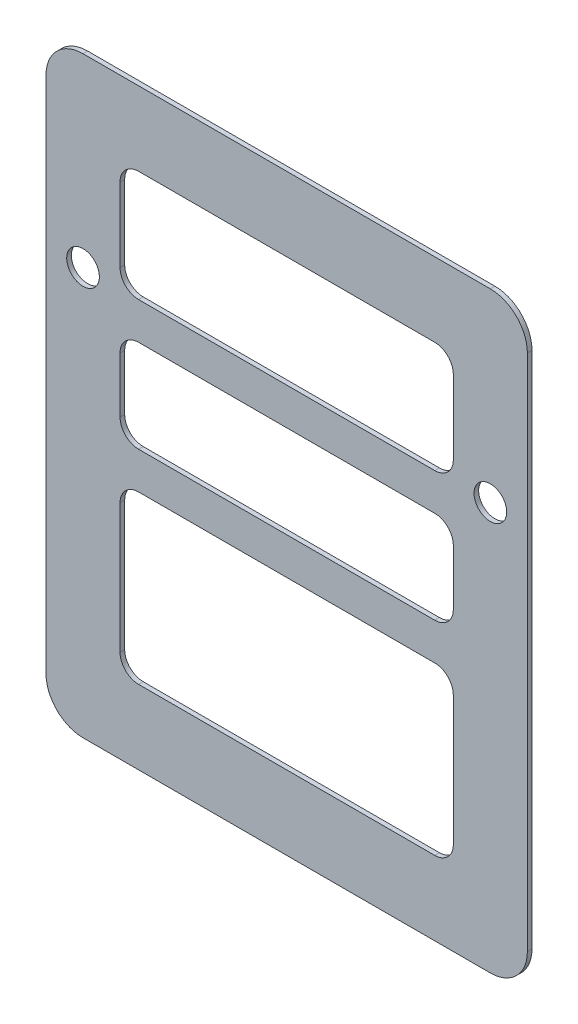
from build123d import *

# Parameters (mm, degrees)
SKETCH1_R           = 11.2
BOSS_EXTRUDE1_DEPTH = 3.175


with BuildPart() as part:
    # Sketch1 → Boss-Extrude1 (new body)
    with BuildSketch(Plane.XY):
        with BuildLine():
            Line((-139.7, -203.2), (139.7, -203.2))
            ThreePointArc((139.7, -203.2), (157.660512242, -195.760512242), (165.1, -177.8))
            Line((165.1, -177.8), (165.1, 177.8))
            ThreePointArc((165.1, 177.8), (157.660512242, 195.760512242), (139.7, 203.2))
            Line((139.7, 203.2), (-139.7, 203.2))
            ThreePointArc((-139.7, 203.2), (-157.660512242, 195.760512242), (-165.1, 177.8))
            Line((-165.1, 177.8), (-165.1, -177.8))
            ThreePointArc((-165.1, -177.8), (-157.660512242, -195.760512242), (-139.7, -203.2))
        make_face()
        with Locations((-139.7, 76.2)):
            Circle(SKETCH1_R, mode=Mode.SUBTRACT)
        with Locations((139.7, 76.2)):
            Circle(SKETCH1_R, mode=Mode.SUBTRACT)
        with BuildLine():
            Line((-101.6, -152.4), (101.6, -152.4))
            ThreePointArc((101.6, -152.4), (110.580256121, -148.680256121), (114.3, -139.7))
            Line((114.3, -139.7), (114.3, -50.8))
            ThreePointArc((114.3, -50.8), (110.580256121, -41.819743879), (101.6, -38.1))
            Line((101.6, -38.1), (-101.6, -38.1))
            ThreePointArc((-101.6, -38.1), (-110.580256121, -41.819743879), (-114.3, -50.8))
            Line((-114.3, -50.8), (-114.3, -139.7))
            ThreePointArc((-114.3, -139.7), (-110.580256121, -148.680256121), (-101.6, -152.4))
        make_face(mode=Mode.SUBTRACT)
        with BuildLine():
            Line((-101.6, -12.7), (101.6, -12.7))
            ThreePointArc((101.6, -12.7), (110.580256121, -8.980256121), (114.3, 0))
            Line((114.3, 0), (114.3, 38.1))
            ThreePointArc((114.3, 38.1), (110.580256121, 47.080256121), (101.6, 50.8))
            Line((101.6, 50.8), (-101.6, 50.8))
            ThreePointArc((-101.6, 50.8), (-110.580256121, 47.080256121), (-114.3, 38.1))
            Line((-114.3, 38.1), (-114.3, 0))
            ThreePointArc((-114.3, 0), (-110.580256121, -8.980256121), (-101.6, -12.7))
        make_face(mode=Mode.SUBTRACT)
        with BuildLine():
            Line((-101.6, 152.4), (101.6, 152.4))
            ThreePointArc((101.6, 152.4), (110.580256121, 148.680256121), (114.3, 139.7))
            Line((114.3, 139.7), (114.3, 88.9))
            ThreePointArc((114.3, 88.9), (110.580256121, 79.919743879), (101.6, 76.2))
            Line((101.6, 76.2), (-101.6, 76.2))
            ThreePointArc((-101.6, 76.2), (-110.580256121, 79.919743879), (-114.3, 88.9))
            Line((-114.3, 88.9), (-114.3, 139.7))
            ThreePointArc((-114.3, 139.7), (-110.580256121, 148.680256121), (-101.6, 152.4))
        make_face(mode=Mode.SUBTRACT)
    extrude(amount=BOSS_EXTRUDE1_DEPTH)


solid = part.part
